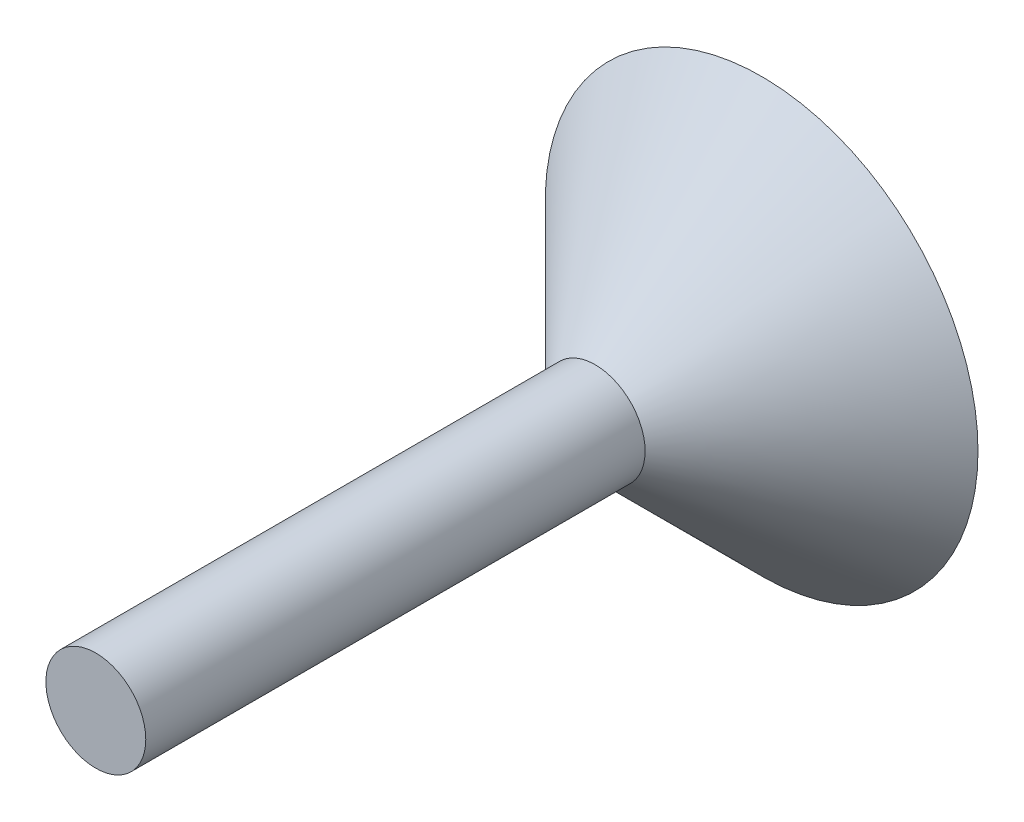
from build123d import *


with BuildPart() as part:
    # Sketch1 → Revolve1 (revolve)
    with BuildSketch(Plane(origin=(0, 0, 0), x_dir=(0, 0, -1), z_dir=(1, 0, 0))):
        Polygon((0, 0), (0, -3), (30, -3), (40, -13), (40, 0), align=None)
    revolve(axis=Axis((0, 0, 0), (0, 0, -1)))


solid = part.part
